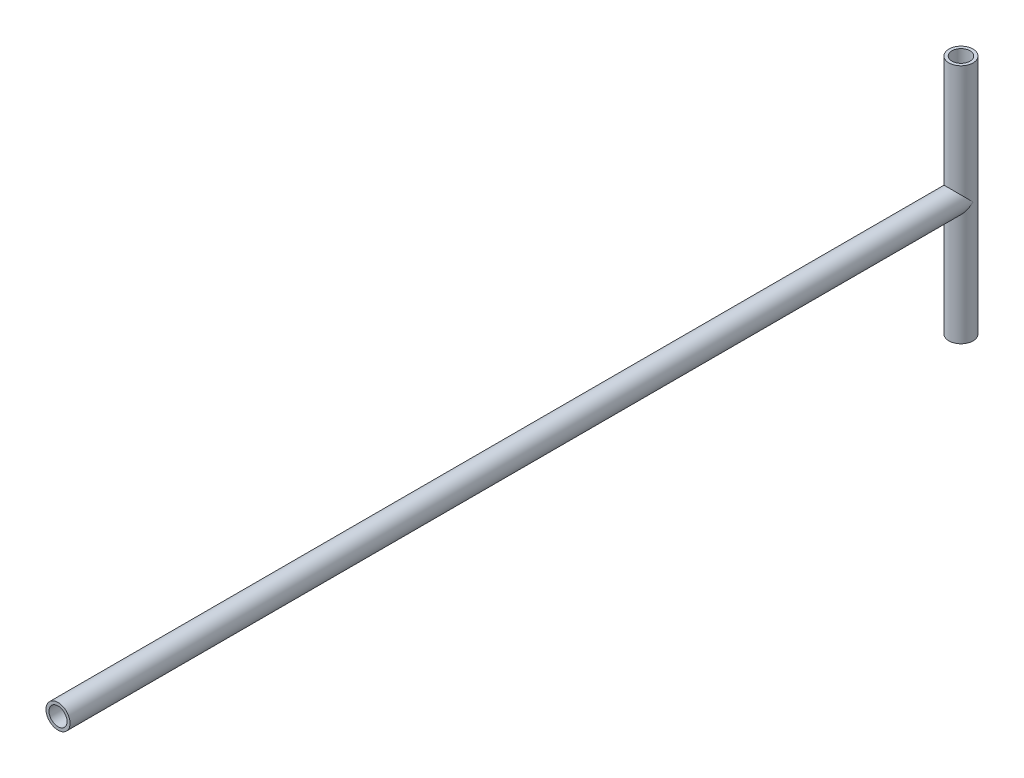
from build123d import *
from build123d.topology import SkipClean

# Parameters (mm, degrees)
SKETCH3_R                = 4
SKETCH3_R_2              = 3
BOSS_EXTRUDE1_DEPTH      = 300
BOSS_EXTRUDE3_DEPTH      = 40
BOSS_EXTRUDE3_DEPTH_BACK = 40
SKETCH6_R                = 4
SKETCH6_R_2              = 3
CUT_EXTRUDE1_DEPTH       = 311.509259244
CUT_EXTRUDE1_DEPTH_BACK  = 311.509259244
SKETCH7_R                = 3


with BuildPart() as part:
    # Sketch3 → Boss-Extrude1 (new body)
    with BuildSketch(Plane.XY):
        Circle(SKETCH3_R)
        Circle(SKETCH3_R_2, mode=Mode.SUBTRACT)
    extrude(amount=BOSS_EXTRUDE1_DEPTH)

    # Sketch6 → Boss-Extrude3 (add, two sides: drawn at the far end of the back side and taken through both)
    with BuildSketch(Plane(origin=(0, 0, 0), x_dir=(1, 0, 0), z_dir=(0, 1, 0)).offset(-BOSS_EXTRUDE3_DEPTH_BACK)):
        Circle(SKETCH6_R)
        Circle(SKETCH6_R_2, mode=Mode.SUBTRACT)
    extrude(amount=BOSS_EXTRUDE3_DEPTH + BOSS_EXTRUDE3_DEPTH_BACK)

    # Sketch7 → Cut-Extrude1 (cut, two sides: drawn at the far end of the back side and taken through both)
    with SkipClean():  # the faces are left unmerged after this step: merging them gives an invalid solid
        with BuildSketch(Plane.XZ.offset(40).offset(-CUT_EXTRUDE1_DEPTH_BACK)):
            Circle(SKETCH7_R)
        extrude(amount=CUT_EXTRUDE1_DEPTH + CUT_EXTRUDE1_DEPTH_BACK, mode=Mode.SUBTRACT)


solid = part.part
